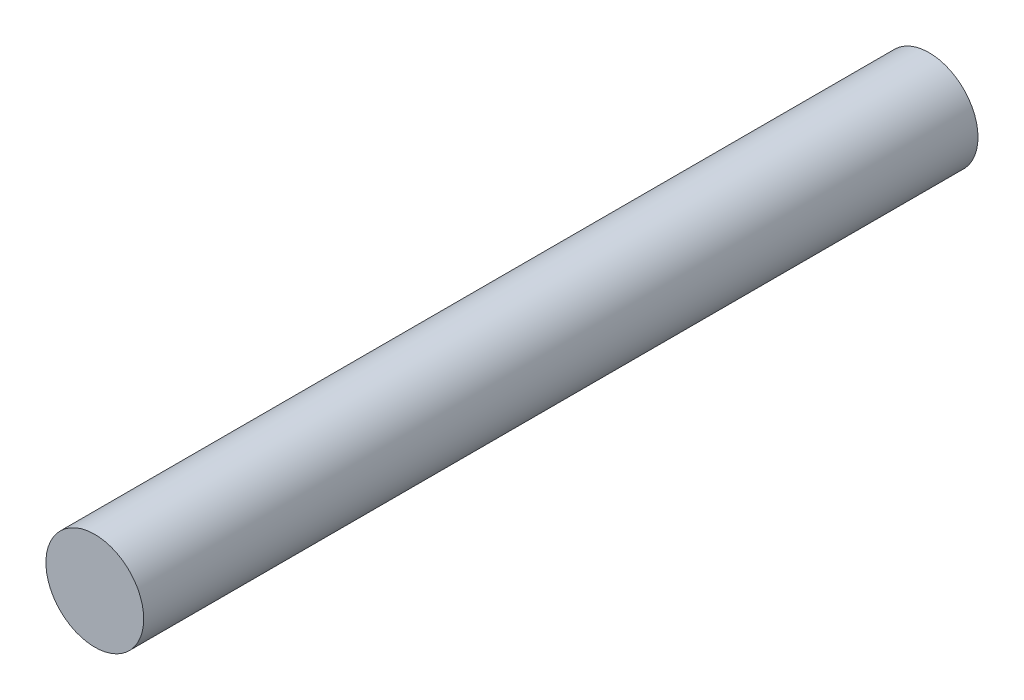
from build123d import *

# Parameters (mm, degrees)
SKETCH1_R           = 1
BOSS_EXTRUDE1_DEPTH = 17.067395495


with BuildPart() as part:
    # Sketch1 → Boss-Extrude1 (new body)
    with BuildSketch(Plane.XY):
        Circle(SKETCH1_R)
    extrude(amount=BOSS_EXTRUDE1_DEPTH)


solid = part.part
